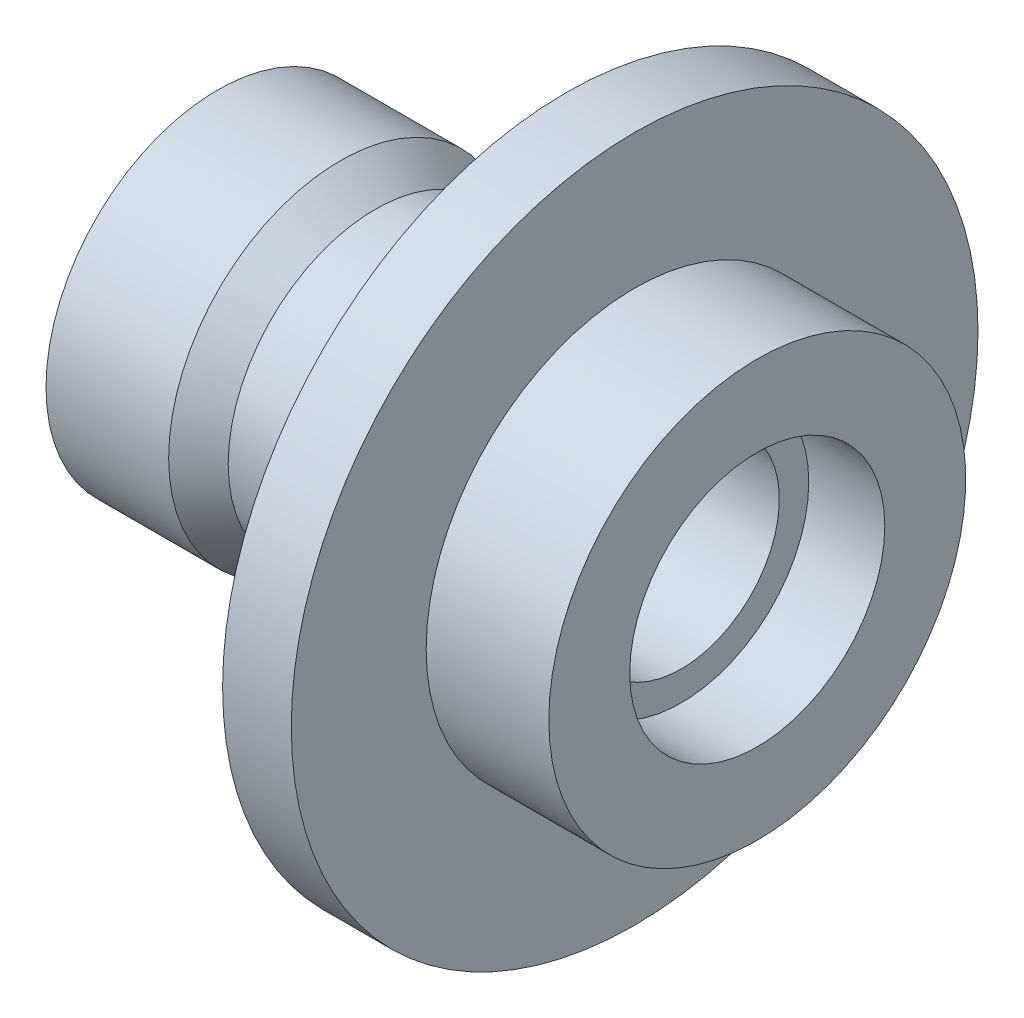
from build123d import *

# Parameters (mm, degrees)
RACCORDO1_R = 3


with BuildPart() as part:
    # Schizzo1 → Rivoluzione1 (revolve)
    with BuildSketch(Plane.XY):
        Polygon((-41.225471698, 23.5), (-27.225471698, 23.5), (-27.225471698, 20), (49.424528302, 20), (49.424528302, 26), (64.924528302, 26), (64.924528302, 42.5), (39.924528302, 42.5), (39.924528302, 70), (25.924528302, 70), (25.924528302, 30), (-12.934731664, 30), (-20.075471698, 35), (-45.075471698, 35), (-45.075471698, 23.5), (-43.075471698, 23.5), (-43.075471698, 24.75), (-41.225471698, 24.75), align=None)
    revolve(axis=Axis((0, 0, 0), (1, 0, 0)))

    # Raccordo1
    raccordo1_edges = [part.edges().sort_by_distance(p)[0] for p in [
        (25.924528302, -30, 0),
    ]]
    fillet(raccordo1_edges, radius=RACCORDO1_R)


solid = part.part
